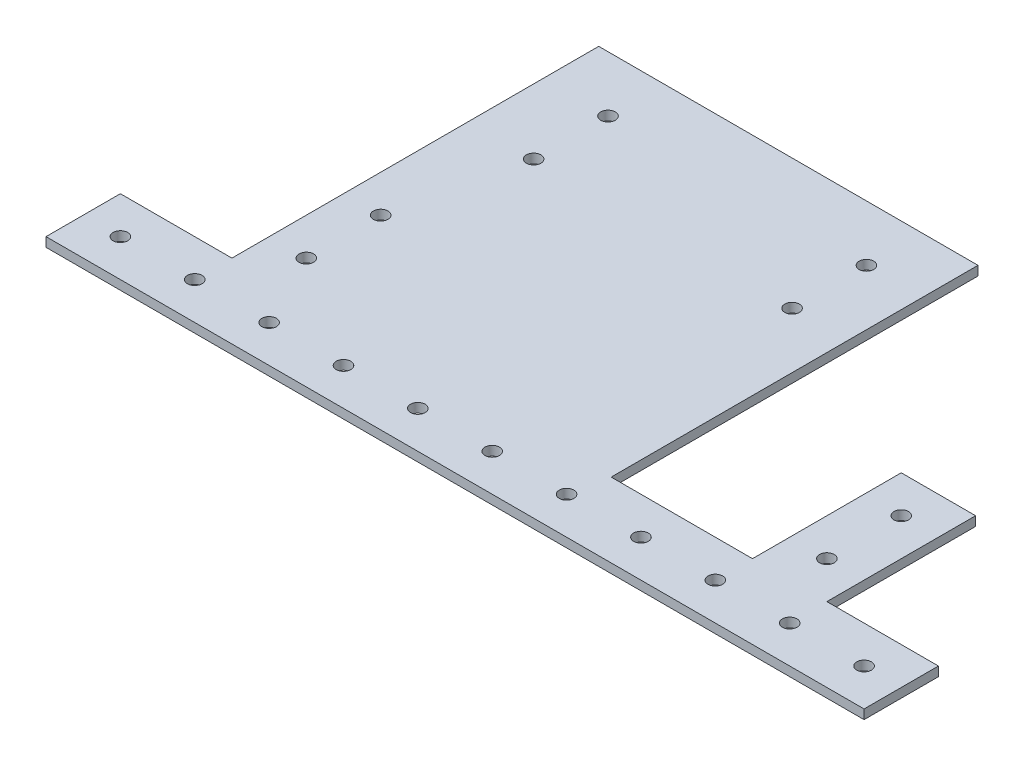
from build123d import *

# Parameters (mm, degrees)
SKETCH1_R           = 2.4892
BOSS_EXTRUDE1_DEPTH = 3.175


with BuildPart() as part:
    # Sketch1 → Boss-Extrude1 (new body)
    with BuildSketch(Plane(origin=(0, 0, 0), x_dir=(1, 0, 0), z_dir=(0, 1, 0))):
        Polygon((139.7, 0), (-139.7, 0), (-139.7, 25.4), (-101.6, 25.4), (-101.6, 150.6728), (27.94, 150.6728), (27.94, 25.4), (76.2, 25.4), (76.2, 76.2), (101.6, 76.2), (101.6, 25.4), (139.7, 25.4), align=None)
        with Locations((-127, 12.7)):
            Circle(SKETCH1_R, mode=Mode.SUBTRACT)
        with Locations((-88.9, 38.1)):
            Circle(SKETCH1_R, mode=Mode.SUBTRACT)
        with Locations((-88.9, 63.5)):
            Circle(SKETCH1_R, mode=Mode.SUBTRACT)
        with Locations((-79.375, 131.6228)):
            Circle(SKETCH1_R, mode=Mode.SUBTRACT)
        with Locations((-79.375, 106.2228)):
            Circle(SKETCH1_R, mode=Mode.SUBTRACT)
        with Locations((8.89, 106.2228)):
            Circle(SKETCH1_R, mode=Mode.SUBTRACT)
        with Locations((8.89, 131.6228)):
            Circle(SKETCH1_R, mode=Mode.SUBTRACT)
        with Locations((88.9, 63.5)):
            Circle(SKETCH1_R, mode=Mode.SUBTRACT)
        with Locations((88.9, 38.1)):
            Circle(SKETCH1_R, mode=Mode.SUBTRACT)
        with Locations((-101.6, 12.7)):
            Circle(SKETCH1_R, mode=Mode.SUBTRACT)
        with Locations((-76.2, 12.7)):
            Circle(SKETCH1_R, mode=Mode.SUBTRACT)
        with Locations((-50.8, 12.7)):
            Circle(SKETCH1_R, mode=Mode.SUBTRACT)
        with Locations((-25.4, 12.7)):
            Circle(SKETCH1_R, mode=Mode.SUBTRACT)
        with Locations((0, 12.7)):
            Circle(SKETCH1_R, mode=Mode.SUBTRACT)
        with Locations((25.4, 12.7)):
            Circle(SKETCH1_R, mode=Mode.SUBTRACT)
        with Locations((50.8, 12.7)):
            Circle(SKETCH1_R, mode=Mode.SUBTRACT)
        with Locations((76.2, 12.7)):
            Circle(SKETCH1_R, mode=Mode.SUBTRACT)
        with Locations((101.6, 12.7)):
            Circle(SKETCH1_R, mode=Mode.SUBTRACT)
        with Locations((127, 12.7)):
            Circle(SKETCH1_R, mode=Mode.SUBTRACT)
    extrude(amount=BOSS_EXTRUDE1_DEPTH)


solid = part.part
